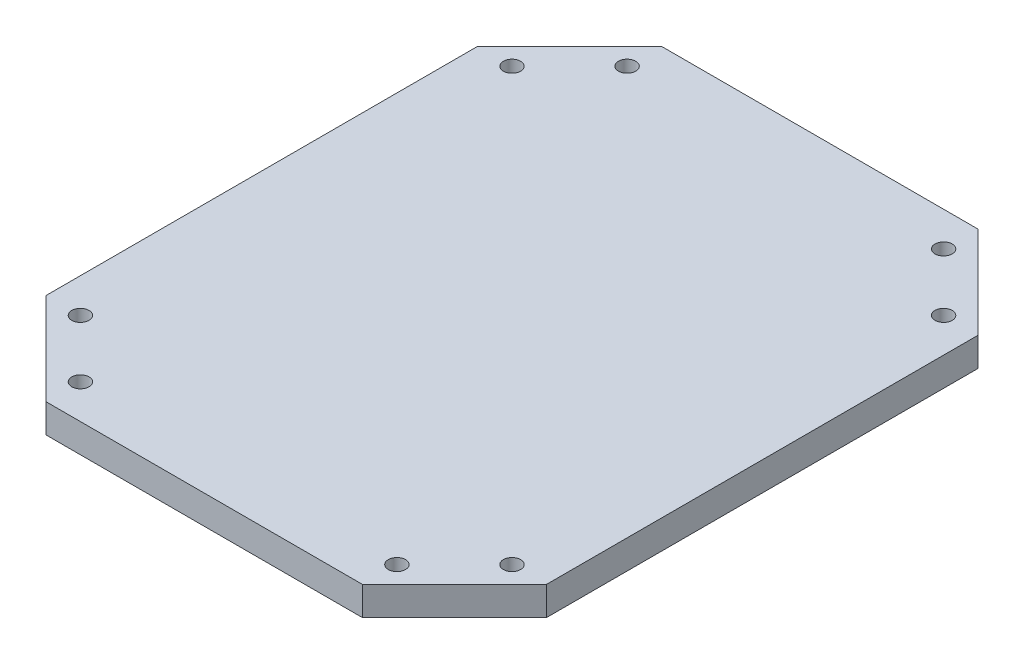
from build123d import *

# Parameters (mm, degrees)
BOSS_EXTRUDE1_DEPTH          = 5
F_3_0_3_DIAMETER_HOLE2_D     = 3
F_3_0_3_DIAMETER_HOLE2_DEPTH = 5
F_3_0_3_DIAMETER_HOLE3_D     = 3
F_3_0_3_DIAMETER_HOLE3_DEPTH = 5
F_3_0_3_DIAMETER_HOLE4_D     = 3
F_3_0_3_DIAMETER_HOLE4_DEPTH = 5


with BuildPart() as part:
    # Sketch1 → Boss-Extrude1 (new body)
    with BuildSketch(Plane(origin=(0, 0, 0), x_dir=(1, 0, 0), z_dir=(0, 1, 0))):
        Polygon((-36.833168475, 10.918963515), (-20.85333758, 26.89879441), (34.14666242, 26.89879441), (50.126493315, 10.918963515), (50.126493315, -64.081036485), (34.14666242, -80.060867381), (-20.85333758, -80.060867381), (-36.833168475, -64.081036485), align=None)
    extrude(amount=BOSS_EXTRUDE1_DEPTH)

    # Ø3.0 (3) Diameter Hole2
    with Locations(Plane(origin=(-30.85333758, 5, -10.918963515), x_dir=(0, 0, 1), z_dir=(0, 1, 0))):
        with Locations((0, 0), (-10, 10)):
            Hole(F_3_0_3_DIAMETER_HOLE2_D / 2, depth=F_3_0_3_DIAMETER_HOLE2_DEPTH)

    # Ø3.0 (3) Diameter Hole3
    with Locations(Plane(origin=(34.14666242, 5, -20.918963515), x_dir=(0, 0, 1), z_dir=(0, 1, 0))):
        with Locations((0, 0), (10, 10)):
            Hole(F_3_0_3_DIAMETER_HOLE3_D / 2, depth=F_3_0_3_DIAMETER_HOLE3_DEPTH)

    # Ø3.0 (3) Diameter Hole4
    with Locations(Plane(origin=(-30.85333758, 5, 64.081036485), x_dir=(0, 0, 1), z_dir=(0, 1, 0))):
        with Locations((0, 0), (10, 10), (10, 65), (0, 75)):
            Hole(F_3_0_3_DIAMETER_HOLE4_D / 2, depth=F_3_0_3_DIAMETER_HOLE4_DEPTH)


solid = part.part
